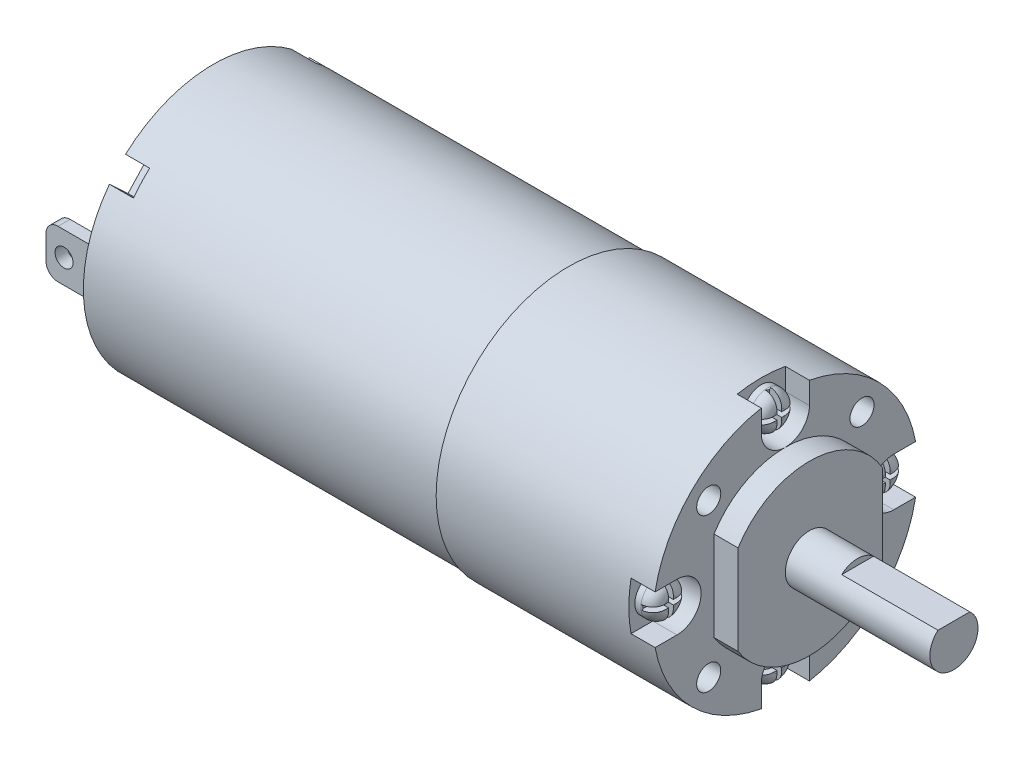
from build123d import *

# Parameters (mm, degrees)
RESSALTO_EXTRUS_O1_DEPTH   = 8
ESBO_O2_R                  = 2
RESSALTO_EXTRUS_O2_DEPTH   = 4
RESSALTO_EXTRUS_O3_DEPTH   = 2
ESBO_O4_R                  = 11
RESSALTO_EXTRUS_O4_DEPTH   = 18
ESBO_O6_R                  = 10.8
RESSALTO_EXTRUS_O5_DEPTH   = 29.5
ESBO_O7_W                  = 1
ESBO_O7_H                  = 4
RESSALTO_EXTRUS_O6_DEPTH   = 3.9
FILETE1_R                  = 1
ESBO_O8_R                  = 0.75
CORTE_EXTRUS_O1_DEPTH      = 1.998581332
CORTE_EXTRUS_O1_DEPTH_BACK = 20
CORTE_EXTRUS_O2_DEPTH      = 2
ESBO_O10_R                 = 1
CORTE_EXTRUS_O3_DEPTH      = 2
CORTE_EXTRUS_O5_DEPTH      = 2
ESBO_O13_R                 = 1.5
RESSALTO_EXTRUS_O7_DEPTH   = 1.5
FILETE2_R                  = 1
CORTE_EXTRUS_O6_DEPTH      = 1


with BuildPart() as part:
    # Esboço1 → Ressalto-extrusão1 (new body)
    with BuildSketch(Plane(origin=(0, 0, 0), x_dir=(0, 0, -1), z_dir=(1, 0, 0))):
        with BuildLine():
            Line((-1.322875656, 1.5), (1.322875656, 1.5))
            ThreePointArc((1.322875656, 1.5), (0, -2), (-1.322875656, 1.5))
        make_face()
    extrude(amount=RESSALTO_EXTRUS_O1_DEPTH)

    # Esboço2 → Ressalto-extrusão2 (add)
    with BuildSketch(Plane.ZY):
        Circle(ESBO_O2_R)
    extrude(amount=RESSALTO_EXTRUS_O2_DEPTH)

    # Esboço3 → Ressalto-extrusão3 (add)
    with BuildSketch(Plane.ZY.offset(4)):
        with BuildLine():
            Line((5.927293497, 3.723867854), (5.927293497, -3.723867854))
            ThreePointArc((5.927293497, -3.723867854), (-0.141235754, -6.998575031), (-6.072706503, -3.481700121))
            Line((-6.072706503, -3.481700121), (-6.072706503, 3.481700121))
            ThreePointArc((-6.072706503, 3.481700121), (-0.141235754, 6.998575031), (5.927293497, 3.723867854))
        make_face()
    extrude(amount=RESSALTO_EXTRUS_O3_DEPTH)

    # Esboço4 → Ressalto-extrusão4 (add)
    with BuildSketch(Plane.ZY.offset(6)):
        Circle(ESBO_O4_R)
    extrude(amount=RESSALTO_EXTRUS_O4_DEPTH)

    # Esboço6 → Ressalto-extrusão5 (add)
    with BuildSketch(Plane.ZY.offset(24)):
        Circle(ESBO_O6_R)
    extrude(amount=RESSALTO_EXTRUS_O5_DEPTH)

    # Esboço7 → Ressalto-extrusão6 (add)
    with BuildSketch(Plane.ZY.offset(53.5)):
        with Locations((-9.498581332, 0.691806914)):
            Rectangle(ESBO_O7_W, ESBO_O7_H)
        with Locations((9.501418668, 0.691806914)):
            Rectangle(ESBO_O7_W, ESBO_O7_H)
    extrude(amount=RESSALTO_EXTRUS_O6_DEPTH)

    # Filete1
    filete1_edges = [part.edges().sort_by_distance(p)[0] for p in [
        (-57.4, -1.308193086, -9.498581332),
        (-57.4, 2.691806914, -9.498581332),
        (-57.4, -1.308193086, 9.501418668),
        (-57.4, 2.691806914, 9.501418668),
    ]]
    fillet(filete1_edges, radius=FILETE1_R)

    # Esboço8 → Corte-extrusão1 (cut, two sides)
    with BuildSketch(Plane.XY.offset(10.001418668)) as corte_extrus_o1_sk:
        with Locations((-55.9, 0.691806914)):
            Circle(ESBO_O8_R)
    extrude(amount=CORTE_EXTRUS_O1_DEPTH, mode=Mode.SUBTRACT)
    extrude(corte_extrus_o1_sk.sketch, amount=-CORTE_EXTRUS_O1_DEPTH_BACK, mode=Mode.SUBTRACT)

    # Esboço9 → Corte-extrusão2 (cut)
    with BuildSketch(Plane(origin=(-6, 0, 0), x_dir=(0, 0, -1), z_dir=(1, 0, 0))):
        with BuildLine():
            Line((-2, 9), (-2, 10.816653826))
            ThreePointArc((-2, 10.816653826), (0, 11), (2, 10.816653826))
            Line((2, 10.816653826), (2, 9))
            ThreePointArc((2, 9), (0, 7), (-2, 9))
        make_face()
        with BuildLine():
            Line((9, 2), (10.816653826, 2))
            ThreePointArc((10.816653826, 2), (11, 0), (10.816653826, -2))
            Line((10.816653826, -2), (9, -2))
            ThreePointArc((9, -2), (7, 0), (9, 2))
        make_face()
        with BuildLine():
            Line((2, -9), (2, -10.816653826))
            ThreePointArc((2, -10.816653826), (0, -11), (-2, -10.816653826))
            Line((-2, -10.816653826), (-2, -9))
            ThreePointArc((-2, -9), (0, -7), (2, -9))
        make_face()
        with BuildLine():
            Line((-9, -2), (-10.816653826, -2))
            ThreePointArc((-10.816653826, -2), (-11, 0), (-10.816653826, 2))
            Line((-10.816653826, 2), (-9, 2))
            ThreePointArc((-9, 2), (-7, 0), (-9, -2))
        make_face()
    extrude(amount=-CORTE_EXTRUS_O2_DEPTH, mode=Mode.SUBTRACT)

    # Esboço10 → Corte-extrusão3 (cut)
    with BuildSketch(Plane(origin=(-6, 0, 0), x_dir=(0, 0, -1), z_dir=(1, 0, 0))):
        with Locations((-6.362921892, 6.365)):
            Circle(ESBO_O10_R)
        with Locations((6.365, 6.362921892)):
            Circle(ESBO_O10_R)
        with Locations((6.362921892, -6.365)):
            Circle(ESBO_O10_R)
        with Locations((-6.365, -6.362921892)):
            Circle(ESBO_O10_R)
    extrude(amount=-CORTE_EXTRUS_O3_DEPTH, mode=Mode.SUBTRACT)

    # Esboço12 → Corte-extrusão5 (cut)
    with BuildSketch(Plane.ZY.offset(53.5)):
        Polygon((-6.507622951, 5.728198296), (-5.044915548, 7.092195016), (-7.090910628, 9.286256121), (-8.553618031, 7.9222594), align=None)
        Polygon((9.286256121, 7.090910628), (7.092195016, 5.044915548), (5.728198296, 6.507622951), (7.9222594, 8.553618031), align=None)
        Polygon((7.090910628, -9.286256121), (5.044915548, -7.092195016), (6.507622951, -5.728198296), (8.553618031, -7.9222594), align=None)
        Polygon((-9.286256121, -7.090910628), (-7.092195016, -5.044915548), (-5.728198296, -6.507622951), (-7.9222594, -8.553618031), align=None)
    extrude(amount=-CORTE_EXTRUS_O5_DEPTH, mode=Mode.SUBTRACT)

    # Esboço13 → Ressalto-extrusão7 (add)
    with BuildSketch(Plane(origin=(-8, 0, 0), x_dir=(0, 0, -1), z_dir=(1, 0, 0))):
        with Locations((-9, 0)):
            Circle(ESBO_O13_R)
        with Locations((0, 9)):
            Circle(ESBO_O13_R)
        with Locations((9, 0)):
            Circle(ESBO_O13_R)
        with Locations((0, -9)):
            Circle(ESBO_O13_R)
    extrude(amount=RESSALTO_EXTRUS_O7_DEPTH)

    # Filete2
    filete2_edges = [part.edges().sort_by_distance(p)[0] for p in [
        (-6.5, 0, 10.5),
        (-6.5, 9, 1.5),
        (-6.5, 0, -7.5),
        (-6.5, -9, 1.5),
    ]]
    fillet(filete2_edges, radius=FILETE2_R)

    # Esboço14 → Corte-extrusão6 (cut)
    with BuildSketch(Plane(origin=(-6.5, 0, 0), x_dir=(0, 0, -1), z_dir=(1, 0, 0))):
        Polygon((-9.2, 1.486606875), (-9.2, 0.2), (-10.486606875, 0.2), (-10.486606875, -0.2), (-9.2, -0.2), (-9.2, -1.486606875), (-8.8, -1.486606875), (-8.8, -0.2), (-7.513393125, -0.2), (-7.513393125, 0.2), (-8.8, 0.2), (-8.8, 1.486606875), align=None)
        Polygon((-0.2, 10.486606875), (-0.2, 9.2), (-1.486606875, 9.2), (-1.486606875, 8.8), (-0.2, 8.8), (-0.2, 7.513393125), (0.2, 7.513393125), (0.2, 8.8), (1.486606875, 8.8), (1.486606875, 9.2), (0.2, 9.2), (0.2, 10.486606875), align=None)
        Polygon((10.486606875, 0.2), (9.2, 0.2), (9.2, 1.486606875), (8.8, 1.486606875), (8.8, 0.2), (7.513393125, 0.2), (7.513393125, -0.2), (8.8, -0.2), (8.8, -1.486606875), (9.2, -1.486606875), (9.2, -0.2), (10.486606875, -0.2), align=None)
        Polygon((0.2, -10.486606875), (0.2, -9.2), (1.486606875, -9.2), (1.486606875, -8.8), (0.2, -8.8), (0.2, -7.513393125), (-0.2, -7.513393125), (-0.2, -8.8), (-1.486606875, -8.8), (-1.486606875, -9.2), (-0.2, -9.2), (-0.2, -10.486606875), align=None)
    extrude(amount=-CORTE_EXTRUS_O6_DEPTH, mode=Mode.SUBTRACT)


solid = part.part
